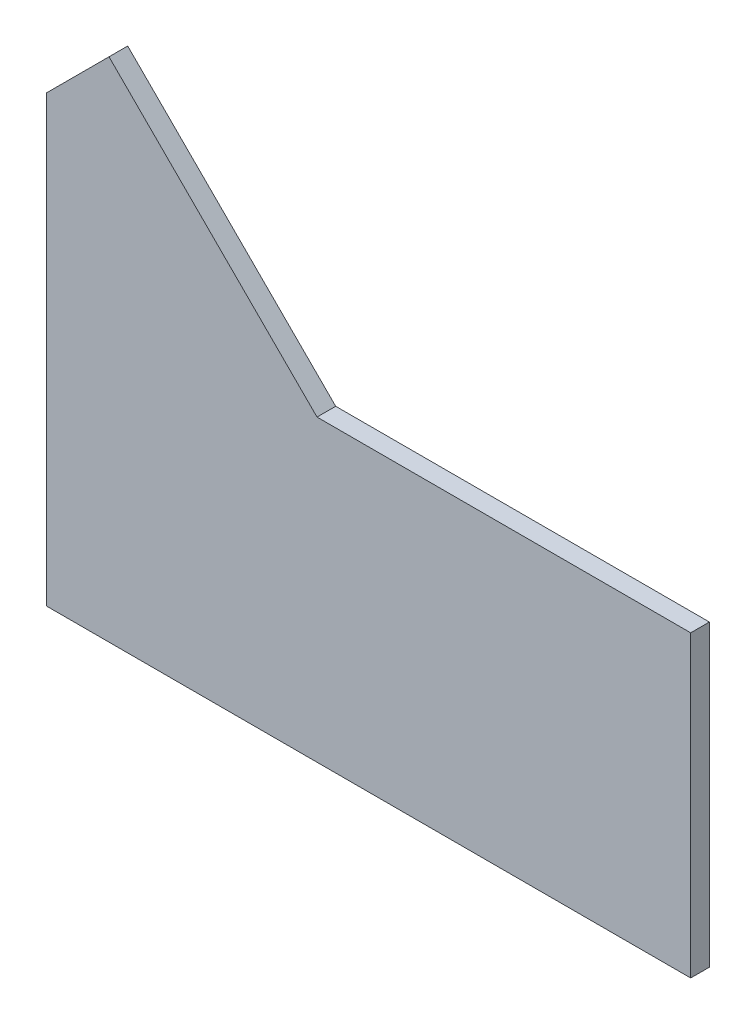
from build123d import *

# Parameters (mm, degrees)
BOSS_EXTRUDE1_DEPTH = 6.35


with BuildPart() as part:
    # Sketch1 → Boss-Extrude1 (new body)
    with BuildSketch(Plane.XY):
        Polygon((0, 0), (127, 0), (127, 101.6), (0, 101.6), (-70.692427737, 172.292427737), (-91.896861793, 151.087993682), (-91.896861793, 0), align=None)
    extrude(amount=BOSS_EXTRUDE1_DEPTH)


solid = part.part
